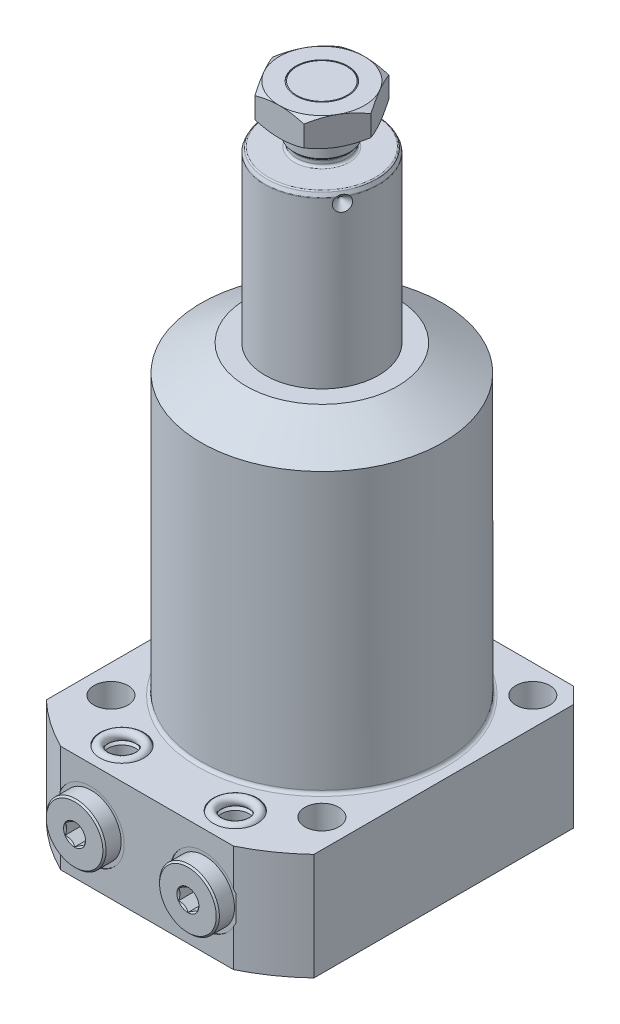
from build123d import *

# Parameters (mm, degrees)
FILLET2_R           = 0.75
FILLET3_R           = 0.5
SKETCH3_R           = 8.25
EXTRUDE3_DEPTH      = 9
CIRPATTERN1_COUNT   = 3
SKETCH7_OUTSIDE_W   = 179.45
SKETCH7_OUTSIDE_H   = 179.45
SKETCH7_OUTSIDE_W_2 = 85
SKETCH7_OUTSIDE_H_2 = 98
CUT_EXTRUDE5_DEPTH  = 191.336371853
SKETCH8_R           = 5.4
CUT_EXTRUDE6_DEPTH  = 183.886576872
CIRPATTERN2_COUNT   = 4
CHAMFER1_SIZE       = 5
FILLET5_R           = 1
CUT_EXTRUDE8_DEPTH  = 5.3
SKETCH16_R          = 1.5


with BuildPart() as part:
    # Sketch1 → Revolve2 (revolve)
    with BuildSketch(Plane.XY, mode=Mode.PRIVATE) as revolve2_sk:
        Polygon((18, 0), (18, 149.5), (17.300538513, 151), (8, 151), (8, 153), (8.935, 153.935), (8.935, 168), (7.935, 169), (0, 169), (0, 0), align=None)
    revolve(revolve2_sk.sketch.rotate(Axis((0, -3.075, 0), (0, 1, 0)), 90), axis=Axis((0, -3.075, 0), (0, 1, 0)))

    # Fillet2
    fillet2_edges = [part.edges().sort_by_distance(p)[0] for p in [
        (0, 151, 8),
        (0, 153, 8),
    ]]
    fillet(fillet2_edges, radius=FILLET2_R)

    # Fillet3
    fillet3_edges = [part.edges().sort_by_distance(p)[0] for p in [
        (0, 149.5, 18),
        (0, 151, 17.300538513),
    ]]
    fillet(fillet3_edges, radius=FILLET3_R)

    # Sketch2 → Cut-Revolve1 (revolve, cut)
    with BuildSketch(Plane(origin=(0, 0, 0), x_dir=(0, 0, -1), z_dir=(1, 0, 0)), mode=Mode.PRIVATE) as cut_revolve1_sk:
        Polygon((15.5, 147.67), (18, 145.17), (18, 147.67), align=None)
    cut_revolve1 = revolve(cut_revolve1_sk.sketch.rotate(Axis((0, 147.67, -4.20155099), (0, 0, -1)), 90), axis=Axis((0, 147.67, -4.20155099), (0, 0, -1)), mode=Mode.SUBTRACT)

    # Sketch3 → Extrude3 (add)
    with BuildSketch(Plane(origin=(0, 169, 0), x_dir=(1, 0, 0), z_dir=(0, 1, 0))):
        Polygon((15.588457268, 0), (7.794228634, 13.5), (-7.794228634, 13.5), (-15.588457268, 0), (-7.794228634, -13.5), (7.794228634, -13.5), align=None)
        with Locations(Location((0, 0, 0), (0, 0, 270))):
            Circle(SKETCH3_R, mode=Mode.SUBTRACT)
    extrude(amount=-EXTRUDE3_DEPTH)

    # CirPattern1: Cut-Revolve1 ×3 about axis
    cirpattern1_axis = Axis((0, -3.075, 0), (0, -1, 0))
    for i in range(1, CIRPATTERN1_COUNT):
        add(cut_revolve1.rotate(cirpattern1_axis, i * 360 / CIRPATTERN1_COUNT), mode=Mode.SUBTRACT)

    # Sketch4 → Cut-Revolve3 (revolve, cut)
    with BuildSketch(Plane(origin=(0, 0, 0), x_dir=(0, 0, -1), z_dir=(1, 0, 0)), mode=Mode.PRIVATE) as cut_revolve3_sk:
        Polygon((13.5, 169), (16.5, 169), (16.5, 167.267949192), align=None)
        Polygon((16.5, 161.732050808), (13.5, 160), (16.5, 160), align=None)
    revolve(cut_revolve3_sk.sketch.rotate(Axis((0, -3.075, 0), (0, -1, 0)), 180), axis=Axis((0, -3.075, 0), (0, -1, 0)), mode=Mode.SUBTRACT)

    # Sketch6 → Revolve3 (revolve)
    with BuildSketch(Plane.XY, mode=Mode.PRIVATE) as revolve3_sk:
        Polygon((0, 97), (24, 97), (38.385, 88.694816378), (38.385, 0), (61.915, 0), (61.915, -34), (0, -34), align=None)
    revolve(revolve3_sk.sketch.rotate(Axis((0, 0, 0), (0, 1, 0)), 85.461391878), axis=Axis((0, 0, 0), (0, 1, 0)))

    # Sketch7 outside → Cut-Extrude5 (cut, through all)
    with BuildSketch(Plane(origin=(0, 0, 0), x_dir=(-1, 0, 0), z_dir=(0, 1, 0))):
        Rectangle(SKETCH7_OUTSIDE_W, SKETCH7_OUTSIDE_H)
        with Locations((0, 6.5)):
            Rectangle(SKETCH7_OUTSIDE_W_2, SKETCH7_OUTSIDE_H_2, mode=Mode.SUBTRACT)
    extrude(amount=-CUT_EXTRUDE5_DEPTH, mode=Mode.SUBTRACT)

    # Sketch8 → Cut-Extrude6 (cut, through all)
    with BuildSketch(Plane(origin=(0, 0, 0), x_dir=(-1, 0, 0), z_dir=(0, 1, 0))):
        with Locations(Location((-33.5, 33.5, 0), (0, 0, 90))):
            Circle(SKETCH8_R)
    cut_extrude6 = extrude(amount=-CUT_EXTRUDE6_DEPTH, mode=Mode.SUBTRACT)

    # CirPattern2: Cut-Extrude6 ×4 about axis
    cirpattern2_axis = Axis((0, 0, 0), (0, 1, 0))
    for i in range(1, CIRPATTERN2_COUNT):
        add(cut_extrude6.rotate(cirpattern2_axis, i * 360 / CIRPATTERN2_COUNT), mode=Mode.SUBTRACT)

    # Chamfer1
    chamfer1_edges = [part.edges().sort_by_distance(p)[0] for p in [
        (-42.5, -17, -42.5),
        (42.5, -17, -42.5),
    ]]
    chamfer(chamfer1_edges, length=CHAMFER1_SIZE)

    # Fillet5
    fillet5_edges = [part.edges().sort_by_distance(p)[0] for p in [
        (-3.037437274, 0, 38.264633799),
    ]]
    fillet(fillet5_edges, radius=FILLET5_R)

    # Sketch11 → Cut-Revolve5 (revolve, cut)
    with BuildSketch(Plane(origin=(0, -17, 0), x_dir=(-1, 0, 0), z_dir=(0, 1, 0))):
        Polygon((-28.75, 55.5), (-28.75, 55.25), (-24.65, 55.25), (-23.945, 54.545), (-23.945, 36.53), (-18, 36.53), (-18, 55.5), align=None)
    cut_revolve5 = revolve(axis=Axis((18, -17, 42.971570338), (0, 0, -1)), mode=Mode.SUBTRACT)

    # Sketch13 → Cut-Revolve6 (revolve, cut)
    with BuildSketch(Plane.XY.offset(45.5)):
        Polygon((-22.375, -22), (-22.375, -31), (-23.125, -31.75), (-25, -31.75), (-25, -34), (-18, -34), (-18, -22), align=None)
    cut_revolve6 = revolve(axis=Axis((-18, 15.209907045, 45.5), (0, -1, 0)), mode=Mode.SUBTRACT)

    # Mirror4: Cut-Revolve6 across plane
    add(cut_revolve6.mirror(Plane.ZX.offset(-17)), mode=Mode.SUBTRACT)

    # Sketch14 → Revolve6 (revolve)
    with BuildSketch(Plane(origin=(0, -17, 0), x_dir=(-1, 0, 0), z_dir=(0, 1, 0)), mode=Mode.PRIVATE) as revolve6_sk:
        Polygon((-21.5, 60.55), (-27, 60.55), (-27.5, 60.05), (-27.5, 55.25), (-23.6, 55.25), (-23.6, 52.74741814), (-18, 52.74741814), (-18, 52.74841814), (-21, 54.550999997), (-21, 60.05), align=None)
    revolve6 = revolve(revolve6_sk.sketch.rotate(Axis((18, -17, 32.588064048), (0, 0, 1)), 180), axis=Axis((18, -17, 32.588064048), (0, 0, 1)))

    # Sketch15 → Cut-Extrude8 (cut)
    with BuildSketch(Plane.XY.offset(60.55)):
        Polygon((21, -18.732050808), (21, -15.267949192), (18, -13.535898385), (15, -15.267949192), (15, -18.732050808), (18, -20.464101615), align=None)
    cut_extrude8 = extrude(amount=-CUT_EXTRUDE8_DEPTH, mode=Mode.SUBTRACT)

    # Mirror1: Cut-Revolve5, Cut-Revolve6, Revolve6, Cut-Extrude8 across plane
    add(cut_revolve5.mirror(Plane(origin=(0, 0, 0), x_dir=(0, 0, 1), z_dir=(1, 0, 0))), mode=Mode.SUBTRACT)
    add(cut_revolve6.mirror(Plane(origin=(0, 0, 0), x_dir=(0, 0, 1), z_dir=(1, 0, 0))), mode=Mode.SUBTRACT)
    add(revolve6.mirror(Plane(origin=(0, 0, 0), x_dir=(0, 0, 1), z_dir=(1, 0, 0))))
    add(cut_extrude8.mirror(Plane(origin=(0, 0, 0), x_dir=(0, 0, 1), z_dir=(1, 0, 0))), mode=Mode.SUBTRACT)

    # Mirror1 copy 1 sketch → Mirror1 copy 1 (revolve, cut)
    with BuildSketch(Plane(origin=(0, -34, 45.5), x_dir=(-1, 0, 0), z_dir=(0, 0, 1))):
        Polygon((-22.375, -22), (-22.375, -31), (-23.125, -31.75), (-25, -31.75), (-25, -34), (-18, -34), (-18, -22), align=None)
    revolve(axis=Axis((18, -49.209907045, 45.5), (0, 1, 0)), mode=Mode.SUBTRACT)


with BuildPart() as body_2:
    # Sketch16 → Revolve7 (revolve)
    with BuildSketch(Plane.XY.offset(45.5), mode=Mode.PRIVATE) as revolve7_sk:
        with Locations((-23.5, -0.75)):
            Circle(SKETCH16_R)
    revolve(revolve7_sk.sketch.rotate(Axis((-18, 9.321927472, 45.5), (0, -1, 0)), 270), axis=Axis((-18, 9.321927472, 45.5), (0, -1, 0)))


with BuildPart() as body_3:
    # Mirror3: mirrored copy
    add(body_2.part.mirror(Plane(origin=(0, 0, 0), x_dir=(0, 0, 1), z_dir=(1, 0, 0))))


with BuildPart() as body_4:
    # Mirror5: mirrored copy
    add(body_2.part.mirror(Plane.ZX.offset(-17)))


with BuildPart() as body_5:
    # Mirror5 2: mirrored copy
    add(body_3.part.mirror(Plane.ZX.offset(-17)))


solid = Compound([part.part, body_2.part, body_3.part, body_4.part, body_5.part])
